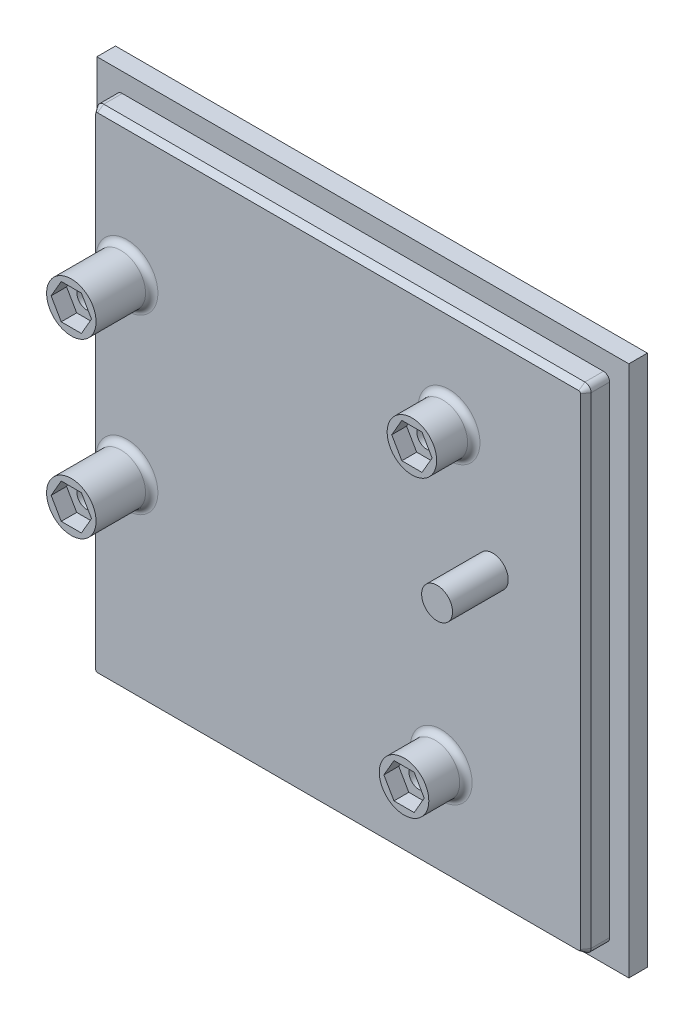
from build123d import *
from OCP.BRepFilletAPI import BRepFilletAPI_MakeChamfer

# Parameters (mm, degrees)
SKETCH1_W           = 86
SKETCH1_H           = 86
BOSS_EXTRUDE1_DEPTH = 3
SKETCH2_W           = 79.8
SKETCH2_H           = 79.8
BOSS_EXTRUDE2_DEPTH = 4
SKETCH3_R           = 4
BOSS_EXTRUDE3_DEPTH = 9
SKETCH5_3_R         = 4
BOSS_EXTRUDE4_DEPTH = 6
FILLET1_R           = 1
CUT_EXTRUDE1_DEPTH  = 2.4
SKETCH5_R           = 1.6
CUT_EXTRUDE2_DEPTH  = 3.6
CUT_EXTRUDE3_DEPTH  = 2.5
SKETCH7_R           = 1.6
CUT_EXTRUDE4_DEPTH  = 6
SKETCH8_R           = 2.5
BOSS_EXTRUDE5_DEPTH = 9
CHAMFER1_SIZE       = 1
CHAMFER1_SIZE2      = 0.700207538


with BuildPart() as part:
    # Sketch1 → Boss-Extrude1 (new body)
    with BuildSketch(Plane.XY):
        Rectangle(SKETCH1_W, SKETCH1_H)
    extrude(amount=BOSS_EXTRUDE1_DEPTH)

    # Sketch2 → Boss-Extrude2 (add)
    with BuildSketch(Plane.XY.offset(3)):
        Rectangle(SKETCH2_W, SKETCH2_H)
    extrude(amount=BOSS_EXTRUDE2_DEPTH)

    # Sketch3 → Boss-Extrude3 (add)
    with BuildSketch(Plane.XY.offset(7)):
        with Locations((-34.14, 18.82)):
            Circle(SKETCH3_R)
        with Locations((-34.14, -9.12)):
            Circle(SKETCH3_R)
    extrude(amount=BOSS_EXTRUDE3_DEPTH)

    # Sketch5_3 → Boss-Extrude4 (add)
    with BuildSketch(Plane.XY.offset(7)):
        with Locations((17.93, 23.9)):
            Circle(SKETCH5_3_R)
        with Locations((16.66, -24.36)):
            Circle(SKETCH5_3_R)
    extrude(amount=BOSS_EXTRUDE4_DEPTH)

    # Fillet1
    fillet1_edges = [part.edges().sort_by_distance(p)[0] for p in [
        (-39.9, -39.9, 5),
        (39.9, -39.9, 5),
        (39.9, 39.9, 5),
        (-39.9, 39.9, 5),
        (-38.14, 18.82, 7),
        (-38.14, -9.12, 7),
        (13.93, 23.9, 7),
        (12.66, -24.36, 7),
    ]]
    fillet(fillet1_edges, radius=FILLET1_R)

    # Sketch4 → Cut-Extrude1 (cut)
    with BuildSketch(Plane.XY.offset(13)):
        Polygon((13.397970979, -24.36), (15.02898549, -27.185), (18.29101451, -27.185), (19.922029021, -24.36), (18.29101451, -21.535), (15.02898549, -21.535), align=None)
        Polygon((14.667970979, 23.9), (16.29898549, 21.075), (19.56101451, 21.075), (21.192029021, 23.9), (19.56101451, 26.725), (16.29898549, 26.725), align=None)
    extrude(amount=-CUT_EXTRUDE1_DEPTH, mode=Mode.SUBTRACT)

    # Sketch5 → Cut-Extrude2 (cut)
    with BuildSketch(Plane.XY.offset(10.6)):
        with Locations((17.93, 23.9)):
            Circle(SKETCH5_R)
        with Locations((16.66, -24.36)):
            Circle(SKETCH5_R)
    extrude(amount=-CUT_EXTRUDE2_DEPTH, mode=Mode.SUBTRACT)

    # Sketch6 → Cut-Extrude3 (cut)
    with BuildSketch(Plane.XY.offset(16)):
        Polygon((-37.402029021, 18.82), (-35.77101451, 15.995), (-32.50898549, 15.995), (-30.877970979, 18.82), (-32.50898549, 21.645), (-35.77101451, 21.645), align=None)
        Polygon((-37.402029021, -9.12), (-35.77101451, -11.945), (-32.50898549, -11.945), (-30.877970979, -9.12), (-32.50898549, -6.295), (-35.77101451, -6.295), align=None)
    extrude(amount=-CUT_EXTRUDE3_DEPTH, mode=Mode.SUBTRACT)

    # Sketch7 → Cut-Extrude4 (cut)
    with BuildSketch(Plane.XY.offset(13.5)):
        with Locations((-34.14, 18.82)):
            Circle(SKETCH7_R)
        with Locations((-34.14, -9.12)):
            Circle(SKETCH7_R)
    extrude(amount=-CUT_EXTRUDE4_DEPTH, mode=Mode.SUBTRACT)

    # Sketch8 → Boss-Extrude5 (add)
    with BuildSketch(Plane.XY.offset(7)):
        with Locations((25, 7)):
            Circle(SKETCH8_R)
    extrude(amount=BOSS_EXTRUDE5_DEPTH)

    # Chamfer1: one chamfer whose edges measure the first distance from different faces: ONE call of the kernel's chamfer builder (chamfer() names one face for all edges)
    chamfer1_edges_1 = [part.edges().sort_by_distance(p)[0] for p in [
        (0, -39.9, 7),
    ]]
    chamfer1_side_1 = [part.faces().sort_by_distance(p)[0] for p in [
        (0, -39.9, 5),
    ]]
    chamfer1_edges_2 = [part.edges().sort_by_distance(p)[0] for p in [
        (39.9, 0, 7),
    ]]
    chamfer1_side_2 = [part.faces().sort_by_distance(p)[0] for p in [
        (39.9, 0, 5),
    ]]
    chamfer1_edges_3 = [part.edges().sort_by_distance(p)[0] for p in [
        (0, 39.9, 7),
    ]]
    chamfer1_side_3 = [part.faces().sort_by_distance(p)[0] for p in [
        (0, 39.9, 5),
    ]]
    chamfer1_edges_4 = [part.edges().sort_by_distance(p)[0] for p in [
        (-39.9, 0, 7),
    ]]
    chamfer1_side_4 = [part.faces().sort_by_distance(p)[0] for p in [
        (-39.9, 0, 5),
    ]]
    chamfer1_edges_5 = [part.edges().sort_by_distance(p)[0] for p in [
        (-39.607106781, 39.607106781, 7),
    ]]
    chamfer1_side_5 = [part.faces().sort_by_distance(p)[0] for p in [
        (-39.607106781, 39.607106781, 5),
    ]]
    chamfer1_edges_6 = [part.edges().sort_by_distance(p)[0] for p in [
        (-39.607106781, -39.607106781, 7),
    ]]
    chamfer1_side_6 = [part.faces().sort_by_distance(p)[0] for p in [
        (-39.607106781, -39.607106781, 5),
    ]]
    chamfer1_edges_7 = [part.edges().sort_by_distance(p)[0] for p in [
        (39.607106781, -39.607106781, 7),
    ]]
    chamfer1_side_7 = [part.faces().sort_by_distance(p)[0] for p in [
        (39.607106781, -39.607106781, 5),
    ]]
    chamfer1_edges_8 = [part.edges().sort_by_distance(p)[0] for p in [
        (39.607106781, 39.607106781, 7),
    ]]
    chamfer1_side_8 = [part.faces().sort_by_distance(p)[0] for p in [
        (39.607106781, 39.607106781, 5),
    ]]
    chamfer1 = BRepFilletAPI_MakeChamfer(part.part.solid().wrapped)
    for e in chamfer1_edges_1:
        chamfer1.Add(CHAMFER1_SIZE, CHAMFER1_SIZE2, e.wrapped, chamfer1_side_1[0].wrapped)  # the first distance lies on this face
    for e in chamfer1_edges_2:
        chamfer1.Add(CHAMFER1_SIZE, CHAMFER1_SIZE2, e.wrapped, chamfer1_side_2[0].wrapped)  # the first distance lies on this face
    for e in chamfer1_edges_3:
        chamfer1.Add(CHAMFER1_SIZE, CHAMFER1_SIZE2, e.wrapped, chamfer1_side_3[0].wrapped)  # the first distance lies on this face
    for e in chamfer1_edges_4:
        chamfer1.Add(CHAMFER1_SIZE, CHAMFER1_SIZE2, e.wrapped, chamfer1_side_4[0].wrapped)  # the first distance lies on this face
    for e in chamfer1_edges_5:
        chamfer1.Add(CHAMFER1_SIZE, CHAMFER1_SIZE2, e.wrapped, chamfer1_side_5[0].wrapped)  # the first distance lies on this face
    for e in chamfer1_edges_6:
        chamfer1.Add(CHAMFER1_SIZE, CHAMFER1_SIZE2, e.wrapped, chamfer1_side_6[0].wrapped)  # the first distance lies on this face
    for e in chamfer1_edges_7:
        chamfer1.Add(CHAMFER1_SIZE, CHAMFER1_SIZE2, e.wrapped, chamfer1_side_7[0].wrapped)  # the first distance lies on this face
    for e in chamfer1_edges_8:
        chamfer1.Add(CHAMFER1_SIZE, CHAMFER1_SIZE2, e.wrapped, chamfer1_side_8[0].wrapped)  # the first distance lies on this face
    add(Compound.cast(chamfer1.Shape()), mode=Mode.REPLACE)


solid = part.part
